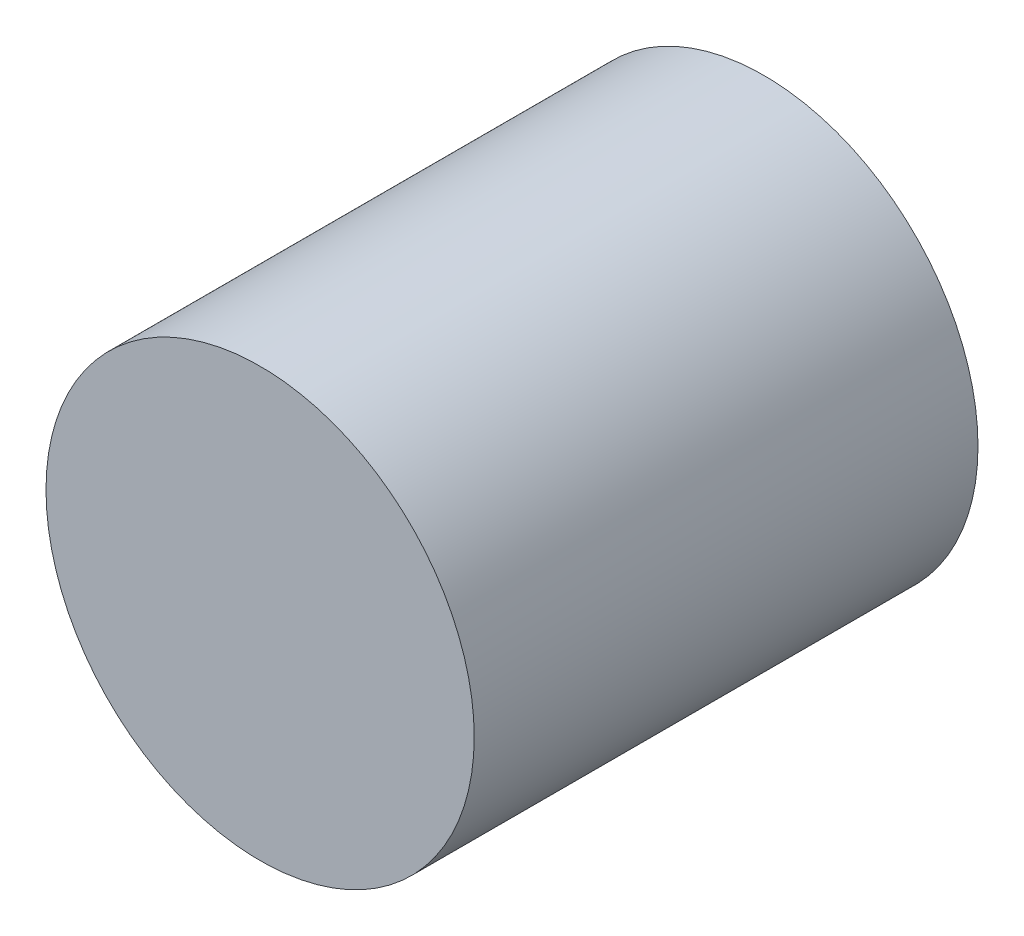
from build123d import *

# Parameters (mm, degrees)
SKETCH_1_R      = 8.5
EXTRUDE_1_DEPTH = 20


with BuildPart() as part:
    # Эскиз1 → Бобышка-Вытянуть1 (new body)
    with BuildSketch(Plane.XY):
        Circle(SKETCH_1_R)
    extrude(amount=EXTRUDE_1_DEPTH)


solid = part.part
